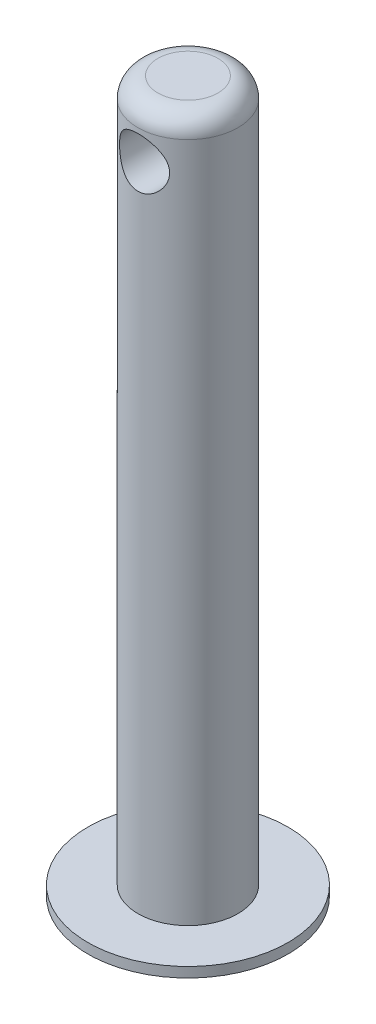
from build123d import *

# Parameters (mm, degrees)
SCHIZZO1_R                    = 5
ESTRUSIONE_ESTRUSIONE1_DEPTH  = 70
RACCORDO1_R                   = 2
SCHIZZO2_R                    = 2.5
TAGLIO_ESTRUSIONE1_DEPTH      = 6
TAGLIO_ESTRUSIONE1_DEPTH_BACK = 6
SCHIZZO3_R                    = 10
ESTRUSIONE_ESTRUSIONE2_DEPTH  = 1


with BuildPart() as part:
    # Schizzo1 → Estrusione-Estrusione1 (new body)
    with BuildSketch(Plane(origin=(0, 0, 0), x_dir=(1, 0, 0), z_dir=(0, 1, 0))):
        Circle(SCHIZZO1_R)
    extrude(amount=ESTRUSIONE_ESTRUSIONE1_DEPTH)

    # Raccordo1
    raccordo1_edges = [part.edges().sort_by_distance(p)[0] for p in [
        (-5, 70, 0),
    ]]
    fillet(raccordo1_edges, radius=RACCORDO1_R)

    # Schizzo2 → Taglio-Estrusione1 (cut, two sides)
    with BuildSketch(Plane.XY) as taglio_estrusione1_sk:
        with Locations((0, 65)):
            Circle(SCHIZZO2_R)
    extrude(amount=TAGLIO_ESTRUSIONE1_DEPTH, mode=Mode.SUBTRACT)
    extrude(taglio_estrusione1_sk.sketch, amount=-TAGLIO_ESTRUSIONE1_DEPTH_BACK, mode=Mode.SUBTRACT)

    # Schizzo3 → Estrusione-Estrusione2 (add)
    with BuildSketch(Plane(origin=(0, 0, 0), x_dir=(-1, 0, 0), z_dir=(0, -1, 0))):
        Circle(SCHIZZO3_R)
    extrude(amount=ESTRUSIONE_ESTRUSIONE2_DEPTH)


solid = part.part
